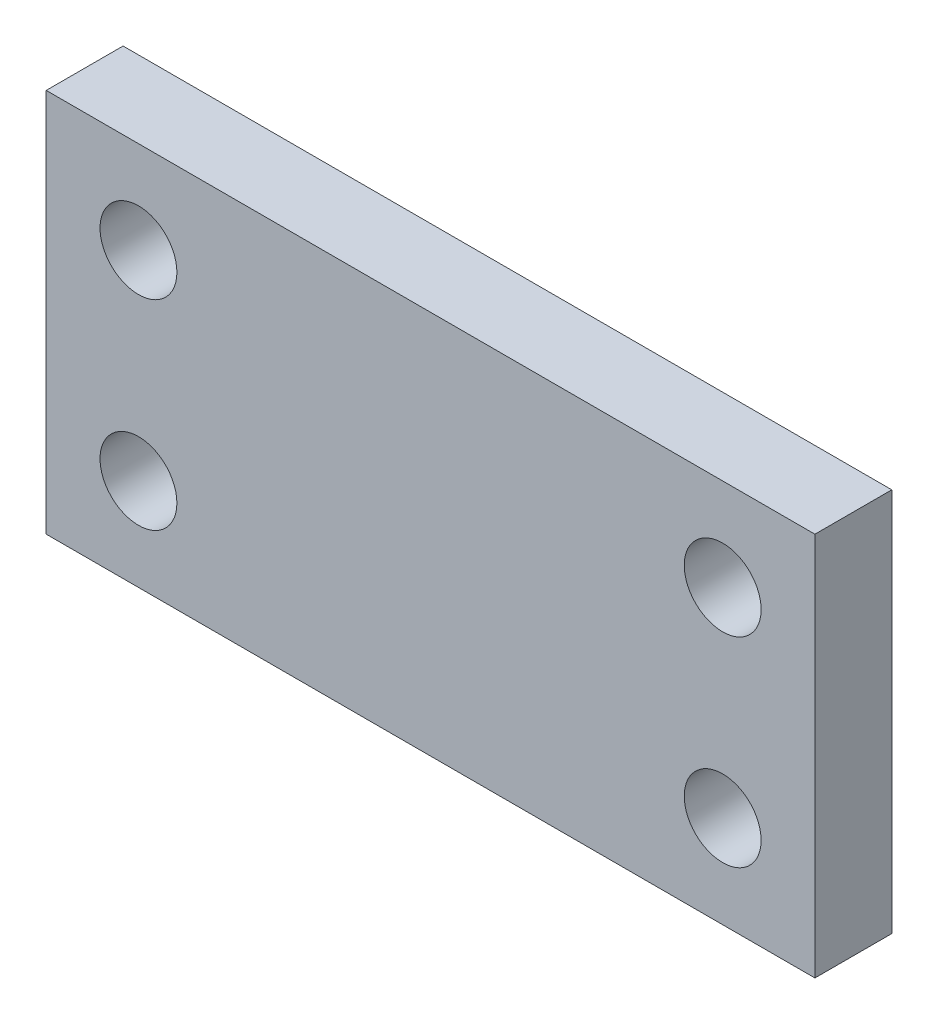
from build123d import *

# Parameters (mm, degrees)
CROQUIS1_W              = 100
CROQUIS1_H              = 50
CROQUIS1_R              = 5
SALIENTE_EXTRUIR1_DEPTH = 10


with BuildPart() as part:
    # Croquis1 → Saliente-Extruir1 (new body)
    with BuildSketch(Plane.XY):
        with Locations((50, 25)):
            Rectangle(CROQUIS1_W, CROQUIS1_H)
        with Locations((12, 38)):
            Circle(CROQUIS1_R, mode=Mode.SUBTRACT)
        with Locations((12, 12)):
            Circle(CROQUIS1_R, mode=Mode.SUBTRACT)
        with Locations((88, 12)):
            Circle(CROQUIS1_R, mode=Mode.SUBTRACT)
        with Locations((88, 38)):
            Circle(CROQUIS1_R, mode=Mode.SUBTRACT)
    extrude(amount=SALIENTE_EXTRUIR1_DEPTH)


solid = part.part
